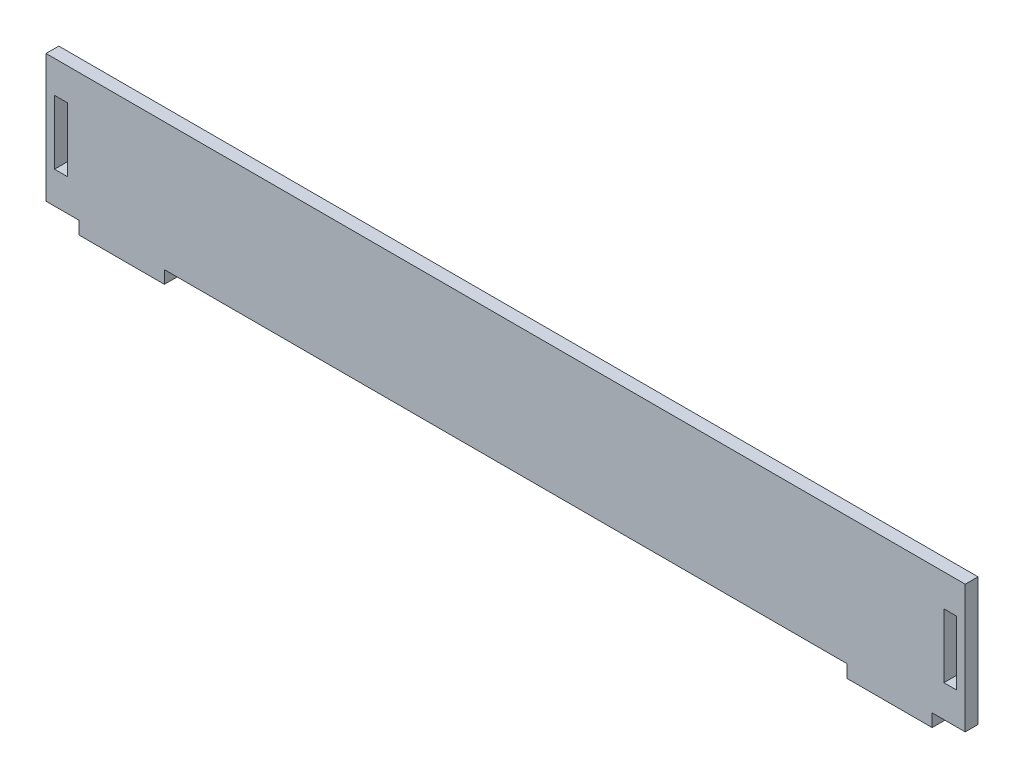
from build123d import *

# Parameters (mm, degrees)
SKETCH_1_W      = 20
SKETCH_1_H      = 3
EXTRUDE_1_DEPTH = 3


with BuildPart() as part:
    # 草图1 → 凸台-拉伸1 (new body)
    with BuildSketch(Plane.XY):
        Polygon((-2.75, 0), (0, 0), (20, 0), (180, 0), (200, 0), (202.75, 0), (207.75, 0), (207.75, 30), (202.75, 30), (200, 30), (0, 30), (-2.75, 30), (-7.75, 30), (-7.75, 0), align=None)
        Polygon((-2.75, 22.5), (-2.75, 15), (-2.75, 7.5), (-5.75, 7.5), (-5.75, 22.5), align=None, mode=Mode.SUBTRACT)
        Polygon((202.75, 7.5), (202.75, 15), (202.75, 22.5), (205.75, 22.5), (205.75, 7.5), align=None, mode=Mode.SUBTRACT)
        with Locations((10, -1.5)):
            Rectangle(SKETCH_1_W, SKETCH_1_H)
        with Locations((190, -1.5)):
            Rectangle(SKETCH_1_W, SKETCH_1_H)
    extrude(amount=EXTRUDE_1_DEPTH)


solid = part.part
